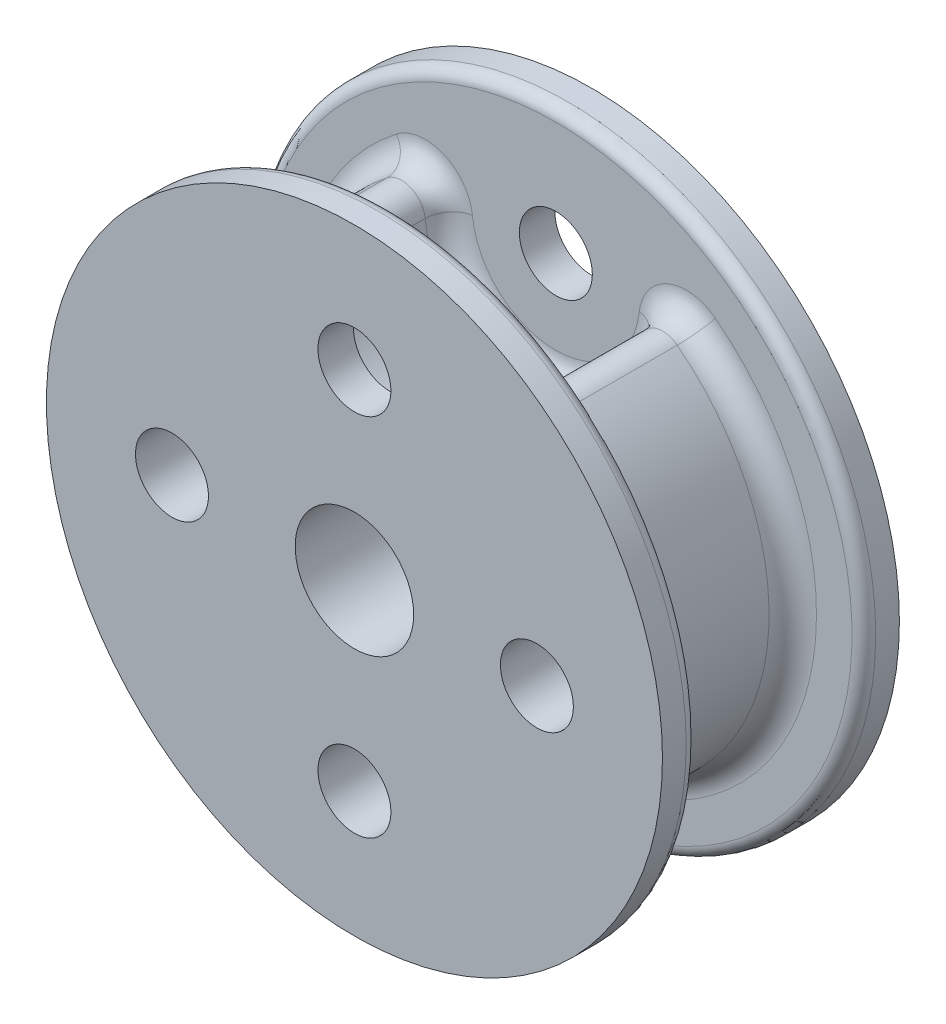
from build123d import *

# Parameters (mm, degrees)
SKETCH2_R           = 1.9558
SKETCH2_R_2         = 3.175
BOSS_EXTRUDE3_DEPTH = 4.445
SKETCH3_R           = 16.51
SKETCH3_R_2         = 1.9558
SKETCH3_R_3         = 3.175
BOSS_EXTRUDE4_DEPTH = 1.905
FILLET1_R           = 1.27
FILLET3_R           = 0.635


with BuildPart() as part:
    # Sketch2 → Boss-Extrude3 (new body, symmetric)
    with BuildSketch(Plane.XY):
        with BuildLine():
            ThreePointArc((-5.522432246, 11.436465455), (-6.751115111, -10.756971914), (12.7, 0))
            ThreePointArc((12.7, 0), (10.756971914, 6.751115111), (5.522432246, 11.436465455))
            ThreePointArc((5.522432246, 11.436465455), (0, 4.0132), (-5.522432246, 11.436465455))
        make_face()
        with Locations((0, -9.779)):
            Circle(SKETCH2_R, mode=Mode.SUBTRACT)
        with Locations((-9.779, 0)):
            Circle(SKETCH2_R, mode=Mode.SUBTRACT)
        Circle(SKETCH2_R_2, mode=Mode.SUBTRACT)
        with Locations((9.779, 0)):
            Circle(SKETCH2_R, mode=Mode.SUBTRACT)
    extrude(amount=BOSS_EXTRUDE3_DEPTH, both=True)

    # Sketch3 → Boss-Extrude4 (add)
    with BuildSketch(Plane.XY.offset(4.445)):
        Circle(SKETCH3_R)
        with Locations((0, -9.779)):
            Circle(SKETCH3_R_2, mode=Mode.SUBTRACT)
        with Locations((9.779, 0)):
            Circle(SKETCH3_R_2, mode=Mode.SUBTRACT)
        Circle(SKETCH3_R_3, mode=Mode.SUBTRACT)
        with Locations((-9.779, 0)):
            Circle(SKETCH3_R_2, mode=Mode.SUBTRACT)
        with Locations((0, 9.779)):
            Circle(SKETCH3_R_2, mode=Mode.SUBTRACT)
    boss_extrude4 = extrude(amount=BOSS_EXTRUDE4_DEPTH)

    # Mirror1: Boss-Extrude4 across plane
    add(boss_extrude4.mirror(Plane.XY))

    # Fillet1
    fillet1_edges = [part.edges().sort_by_distance(p)[0] for p in [
        (-6.751115111, -10.756971914, -4.445),
        (0, 4.0132, -4.445),
        (5.522432246, 11.436465455, -2.2225),
        (-5.522432246, 11.436465455, -2.2225),
        (0, 4.0132, 4.445),
        (-6.751115111, -10.756971914, 4.445),
    ]]
    fillet(fillet1_edges, radius=FILLET1_R)

    # Fillet3
    fillet3_edges = [part.edges().sort_by_distance(p)[0] for p in [
        (-16.51, 0, 4.445),
        (-16.51, 0, -4.445),
    ]]
    fillet(fillet3_edges, radius=FILLET3_R)


solid = part.part
